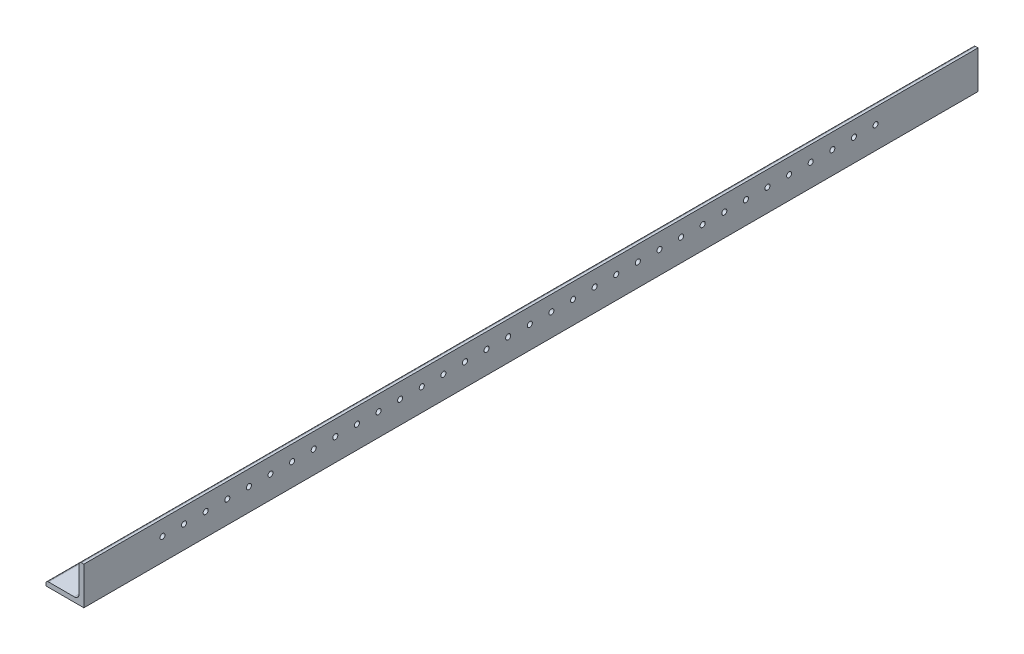
from build123d import *

# Parameters (mm, degrees)
BOSS_EXTRUDE1_DEPTH = 609.6
SKETCH3_W           = 619.2
SKETCH3_H           = 25.4
CUT_EXTRUDE2_DEPTH  = 30.48
SKETCH5_R           = 1.7
CUT_EXTRUDE3_DEPTH  = 611.137198198
SKETCH7_R           = 1.7
CUT_EXTRUDE4_DEPTH  = 611.137198198


with BuildPart() as part:
    # Sketch2 → Boss-Extrude1 (new, symmetric)
    with BuildSketch(Plane.XY):
        with BuildLine():
            Line((-12.7, -12.7), (12.7, -12.7))
            Line((12.7, -12.7), (12.7, 12.7))
            Line((12.7, 12.7), (11.1125, 12.7))
            ThreePointArc((11.1125, 12.7), (9.989967985, 12.235032015), (9.525, 11.1125))
            Line((9.525, 11.1125), (9.525, -6.35))
            ThreePointArc((9.525, -6.35), (8.59506403, -8.59506403), (6.35, -9.525))
            Line((6.35, -9.525), (-11.1125, -9.525))
            ThreePointArc((-11.1125, -9.525), (-12.235032015, -9.989967985), (-12.7, -11.1125))
            Line((-12.7, -11.1125), (-12.7, -12.7))
        make_face()
    extrude(amount=BOSS_EXTRUDE1_DEPTH, both=True)

    # Sketch3 → Cut-Extrude2 (cut)
    with BuildSketch(Plane(origin=(12.7, 0, 0), x_dir=(0, 0, -1), z_dir=(1, 0, 0))):
        with Locations((300, 0)):
            Rectangle(SKETCH3_W, SKETCH3_H)
    extrude(amount=-CUT_EXTRUDE2_DEPTH, mode=Mode.SUBTRACT)

    # Sketch5 → Cut-Extrude3 (cut, through all)
    with BuildSketch(Plane.ZY.offset(-9.525)):
        with Locations(Location((78.35, 2.38125, 0), (0, 0, 270))):
            Circle(SKETCH5_R)
        with Locations(Location((92.85, 2.38125, 0), (0, 0, 270))):
            Circle(SKETCH5_R)
        with Locations(Location((107.35, 2.38125, 0), (0, 0, 270))):
            Circle(SKETCH5_R)
        with Locations(Location((121.85, 2.38125, 0), (0, 0, 270))):
            Circle(SKETCH5_R)
        with Locations(Location((136.35, 2.38125, 0), (0, 0, 270))):
            Circle(SKETCH5_R)
        with Locations(Location((150.85, 2.38125, 0), (0, 0, 270))):
            Circle(SKETCH5_R)
        with Locations(Location((165.35, 2.38125, 0), (0, 0, 270))):
            Circle(SKETCH5_R)
        with Locations(Location((179.85, 2.38125, 0), (0, 0, 270))):
            Circle(SKETCH5_R)
        with Locations(Location((194.35, 2.38125, 0), (0, 0, 270))):
            Circle(SKETCH5_R)
        with Locations(Location((208.85, 2.38125, 0), (0, 0, 270))):
            Circle(SKETCH5_R)
        with Locations(Location((223.35, 2.38125, 0), (0, 0, 270))):
            Circle(SKETCH5_R)
        with Locations(Location((237.85, 2.38125, 0), (0, 0, 270))):
            Circle(SKETCH5_R)
        with Locations(Location((252.35, 2.38125, 0), (0, 0, 270))):
            Circle(SKETCH5_R)
        with Locations(Location((266.85, 2.38125, 0), (0, 0, 270))):
            Circle(SKETCH5_R)
        with Locations(Location((281.35, 2.38125, 0), (0, 0, 270))):
            Circle(SKETCH5_R)
        with Locations(Location((295.85, 2.38125, 0), (0, 0, 270))):
            Circle(SKETCH5_R)
        with Locations(Location((310.35, 2.38125, 0), (0, 0, 270))):
            Circle(SKETCH5_R)
        with Locations(Location((324.85, 2.38125, 0), (0, 0, 270))):
            Circle(SKETCH5_R)
        with Locations(Location((339.35, 2.38125, 0), (0, 0, 270))):
            Circle(SKETCH5_R)
        with Locations(Location((353.85, 2.38125, 0), (0, 0, 270))):
            Circle(SKETCH5_R)
        with Locations(Location((368.35, 2.38125, 0), (0, 0, 270))):
            Circle(SKETCH5_R)
        with Locations(Location((382.85, 2.38125, 0), (0, 0, 270))):
            Circle(SKETCH5_R)
        with Locations(Location((397.35, 2.38125, 0), (0, 0, 270))):
            Circle(SKETCH5_R)
        with Locations(Location((411.85, 2.38125, 0), (0, 0, 270))):
            Circle(SKETCH5_R)
        with Locations(Location((426.35, 2.38125, 0), (0, 0, 270))):
            Circle(SKETCH5_R)
        with Locations(Location((440.85, 2.38125, 0), (0, 0, 270))):
            Circle(SKETCH5_R)
        with Locations(Location((455.35, 2.38125, 0), (0, 0, 270))):
            Circle(SKETCH5_R)
        with Locations(Location((469.85, 2.38125, 0), (0, 0, 270))):
            Circle(SKETCH5_R)
        with Locations(Location((484.35, 2.38125, 0), (0, 0, 270))):
            Circle(SKETCH5_R)
        with Locations(Location((498.85, 2.38125, 0), (0, 0, 270))):
            Circle(SKETCH5_R)
        with Locations(Location((513.35, 2.38125, 0), (0, 0, 270))):
            Circle(SKETCH5_R)
        with Locations(Location((527.85, 2.38125, 0), (0, 0, 270))):
            Circle(SKETCH5_R)
        with Locations(Location((542.35, 2.38125, 0), (0, 0, 270))):
            Circle(SKETCH5_R)
        with Locations(Location((556.85, 2.38125, 0), (0, 0, 270))):
            Circle(SKETCH5_R)
    extrude(amount=-CUT_EXTRUDE3_DEPTH, mode=Mode.SUBTRACT)

    # Sketch7 → Cut-Extrude4 (cut, through all)
    with BuildSketch(Plane(origin=(0, -9.525, 0), x_dir=(1, 0, 0), z_dir=(0, 1, 0))):
        with Locations(Location((-2.38125, -78.35, 0), (0, 0, 180))):
            Circle(SKETCH7_R)
        with Locations(Location((-2.38125, -92.85, 0), (0, 0, 180))):
            Circle(SKETCH7_R)
        with Locations(Location((-2.38125, -107.35, 0), (0, 0, 180))):
            Circle(SKETCH7_R)
        with Locations(Location((-2.38125, -121.85, 0), (0, 0, 180))):
            Circle(SKETCH7_R)
        with Locations(Location((-2.38125, -136.35, 0), (0, 0, 180))):
            Circle(SKETCH7_R)
        with Locations(Location((-2.38125, -150.85, 0), (0, 0, 180))):
            Circle(SKETCH7_R)
        with Locations(Location((-2.38125, -165.35, 0), (0, 0, 180))):
            Circle(SKETCH7_R)
        with Locations(Location((-2.38125, -179.85, 0), (0, 0, 180))):
            Circle(SKETCH7_R)
        with Locations(Location((-2.38125, -194.35, 0), (0, 0, 180))):
            Circle(SKETCH7_R)
        with Locations(Location((-2.38125, -208.85, 0), (0, 0, 180))):
            Circle(SKETCH7_R)
        with Locations(Location((-2.38125, -223.35, 0), (0, 0, 180))):
            Circle(SKETCH7_R)
        with Locations(Location((-2.38125, -237.85, 0), (0, 0, 180))):
            Circle(SKETCH7_R)
        with Locations(Location((-2.38125, -252.35, 0), (0, 0, 180))):
            Circle(SKETCH7_R)
        with Locations(Location((-2.38125, -266.85, 0), (0, 0, 180))):
            Circle(SKETCH7_R)
        with Locations(Location((-2.38125, -281.35, 0), (0, 0, 180))):
            Circle(SKETCH7_R)
        with Locations(Location((-2.38125, -295.85, 0), (0, 0, 180))):
            Circle(SKETCH7_R)
        with Locations(Location((-2.38125, -310.35, 0), (0, 0, 180))):
            Circle(SKETCH7_R)
        with Locations(Location((-2.38125, -324.85, 0), (0, 0, 180))):
            Circle(SKETCH7_R)
        with Locations(Location((-2.38125, -339.35, 0), (0, 0, 180))):
            Circle(SKETCH7_R)
        with Locations(Location((-2.38125, -353.85, 0), (0, 0, 180))):
            Circle(SKETCH7_R)
        with Locations(Location((-2.38125, -368.35, 0), (0, 0, 180))):
            Circle(SKETCH7_R)
        with Locations(Location((-2.38125, -382.85, 0), (0, 0, 180))):
            Circle(SKETCH7_R)
        with Locations(Location((-2.38125, -397.35, 0), (0, 0, 180))):
            Circle(SKETCH7_R)
        with Locations(Location((-2.38125, -411.85, 0), (0, 0, 180))):
            Circle(SKETCH7_R)
        with Locations(Location((-2.38125, -426.35, 0), (0, 0, 180))):
            Circle(SKETCH7_R)
        with Locations(Location((-2.38125, -440.85, 0), (0, 0, 180))):
            Circle(SKETCH7_R)
        with Locations(Location((-2.38125, -455.35, 0), (0, 0, 180))):
            Circle(SKETCH7_R)
        with Locations(Location((-2.38125, -469.85, 0), (0, 0, 180))):
            Circle(SKETCH7_R)
        with Locations(Location((-2.38125, -484.35, 0), (0, 0, 180))):
            Circle(SKETCH7_R)
        with Locations(Location((-2.38125, -498.85, 0), (0, 0, 180))):
            Circle(SKETCH7_R)
        with Locations(Location((-2.38125, -513.35, 0), (0, 0, 180))):
            Circle(SKETCH7_R)
        with Locations(Location((-2.38125, -527.85, 0), (0, 0, 180))):
            Circle(SKETCH7_R)
        with Locations(Location((-2.38125, -542.35, 0), (0, 0, 180))):
            Circle(SKETCH7_R)
        with Locations(Location((-2.38125, -556.85, 0), (0, 0, 180))):
            Circle(SKETCH7_R)
    extrude(amount=-CUT_EXTRUDE4_DEPTH, mode=Mode.SUBTRACT)


solid = part.part
